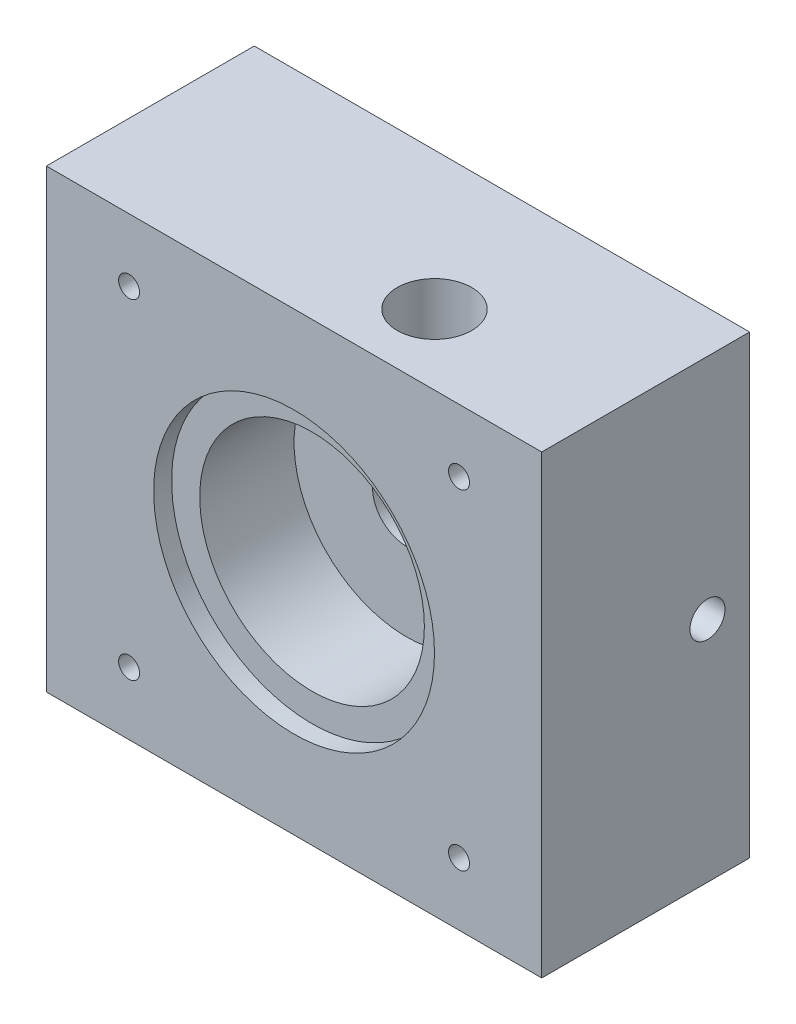
from build123d import *

# Parameters (mm, degrees)
SKETCH1_W               = 56
SKETCH1_H               = 51.5
BOSS_EXTRUDE1_DEPTH     = 23.5
SKETCH2_R               = 15.875
CUT_EXTRUDE1_DEPTH      = 2.032
SKETCH3_R               = 12.7
CUT_EXTRUDE2_DEPTH      = 10.668
SKETCH4_R               = 3.8354
CUT_EXTRUDE3_DEPTH      = 11.8
SKETCH5_R               = 6.35
CUT_EXTRUDE4_DEPTH      = 2.794
SKETCH6_R               = 4.2164
CUT_EXTRUDE5_DEPTH      = 25.4
SKETCH7_R               = 1.984375
CUT_EXTRUDE6_DEPTH      = 6.35
SKETCH8_R               = 1.984375
CUT_EXTRUDE7_DEPTH      = 11.1125
SKETCH9_R               = 1.1811
CUT_EXTRUDE8_DEPTH      = 24.5
MIRROR4_COPY_1_SKETCH_R = 1.1811
MIRROR4_COPY_1_DEPTH    = 24.5


with BuildPart() as part:
    # Sketch1 → Boss-Extrude1 (new body)
    with BuildSketch(Plane.XY):
        Rectangle(SKETCH1_W, SKETCH1_H)
    extrude(amount=BOSS_EXTRUDE1_DEPTH)

    # Sketch2 → Cut-Extrude1 (cut)
    with BuildSketch(Plane.XY.offset(23.5)):
        Circle(SKETCH2_R)
    extrude(amount=-CUT_EXTRUDE1_DEPTH, mode=Mode.SUBTRACT)

    # Sketch3 → Cut-Extrude2 (cut)
    with BuildSketch(Plane.XY.offset(21.468)):
        Circle(SKETCH3_R)
    extrude(amount=-CUT_EXTRUDE2_DEPTH, mode=Mode.SUBTRACT)

    # Sketch4 → Cut-Extrude3 (cut, through all)
    with BuildSketch(Plane.XY.offset(10.8)):
        Circle(SKETCH4_R)
    extrude(amount=-CUT_EXTRUDE3_DEPTH, mode=Mode.SUBTRACT)

    # Sketch5 → Cut-Extrude4 (cut)
    with BuildSketch(Plane(origin=(0, 0, 0), x_dir=(-1, 0, 0), z_dir=(0, 0, -1))):
        Circle(SKETCH5_R)
    extrude(amount=-CUT_EXTRUDE4_DEPTH, mode=Mode.SUBTRACT)

    # Sketch6 → Cut-Extrude5 (cut)
    with BuildSketch(Plane(origin=(0, 25.75, 0), x_dir=(1, 0, 0), z_dir=(0, 1, 0))):
        with Locations((7.9375, -15.5625)):
            Circle(SKETCH6_R)
    extrude(amount=-CUT_EXTRUDE5_DEPTH, mode=Mode.SUBTRACT)

    # Sketch7 → Cut-Extrude6 (cut)
    with BuildSketch(Plane(origin=(0, 0, 0), x_dir=(-1, 0, 0), z_dir=(0, 0, -1))):
        with Locations((-18.475, 0)):
            Circle(SKETCH7_R)
    cut_extrude6 = extrude(amount=-CUT_EXTRUDE6_DEPTH, mode=Mode.SUBTRACT)

    # Mirror1: Cut-Extrude6 across plane
    add(cut_extrude6.mirror(Plane(origin=(0, 0, 0), x_dir=(0, 0, 1), z_dir=(1, 0, 0))), mode=Mode.SUBTRACT)

    # Sketch8 → Cut-Extrude7 (cut)
    with BuildSketch(Plane(origin=(28, 0, 0), x_dir=(0, 0, -1), z_dir=(1, 0, 0))):
        with Locations((-4.7625, 0)):
            Circle(SKETCH8_R)
    cut_extrude7 = extrude(amount=-CUT_EXTRUDE7_DEPTH, mode=Mode.SUBTRACT)

    # Mirror2: Cut-Extrude7 across plane
    add(cut_extrude7.mirror(Plane(origin=(0, 0, 0), x_dir=(0, 0, 1), z_dir=(1, 0, 0))), mode=Mode.SUBTRACT)

    # Sketch9 → Cut-Extrude8 (cut, through all)
    with BuildSketch(Plane.XY.offset(23.5)):
        with Locations((18.65, 18.65)):
            Circle(SKETCH9_R)
    cut_extrude8 = extrude(amount=-CUT_EXTRUDE8_DEPTH, mode=Mode.SUBTRACT)

    # Mirror3: Cut-Extrude8 across plane
    add(cut_extrude8.mirror(Plane.ZX), mode=Mode.SUBTRACT)

    # Mirror4: Cut-Extrude8 across plane
    add(cut_extrude8.mirror(Plane(origin=(0, 0, 0), x_dir=(0, 0, 1), z_dir=(1, 0, 0))), mode=Mode.SUBTRACT)

    # Mirror4 copy 1 sketch → Mirror4 copy 1 (cut, through all)
    with BuildSketch(Plane(origin=(0, 0, 23.5), x_dir=(-1, 0, 0), z_dir=(0, 0, 1))):
        with Locations((18.65, 18.65)):
            Circle(MIRROR4_COPY_1_SKETCH_R)
    extrude(amount=-MIRROR4_COPY_1_DEPTH, mode=Mode.SUBTRACT)


solid = part.part
